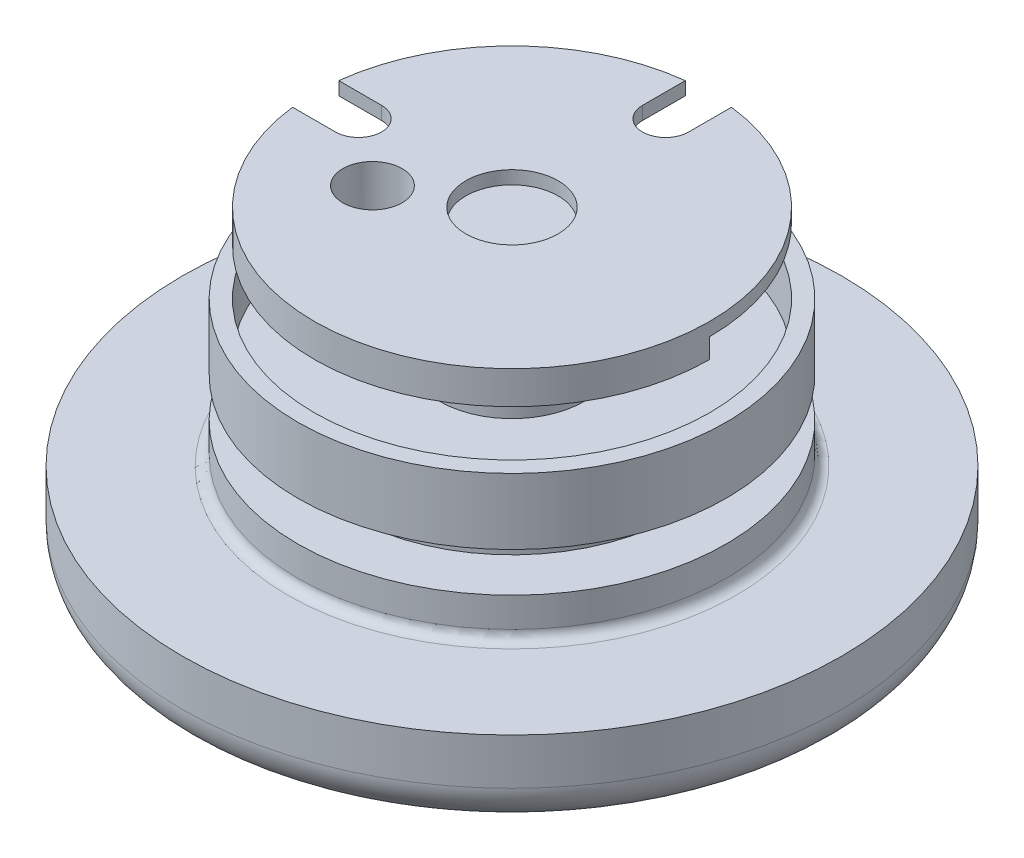
from build123d import *

# Parameters (mm, degrees)
CROQUIS1_R               = 50
SALIENTE_EXTRUIR1_DEPTH  = 13
CROQUIS1_3_R             = 38.5
CORTAR_EXTRUIR1_DEPTH    = 4
CROQUIS4_R               = 14
CROQUIS4_R_2             = 11
SALIENTE_EXTRUIR3_DEPTH  = 6
CROQUIS4_2_R             = 11
CORTAR_EXTRUIR4_DEPTH    = 10
REDONDEO1_R              = 1.5
REDONDEO2_R              = 1.5
REDONDEO3_R              = 6
CROQUIS7_R               = 32.5
CROQUIS7_R_2             = 11
SALIENTE_EXTRUIR4_DEPTH  = 6
REDONDEO4_R              = 1.5
CROQUIS9_R               = 25
CROQUIS9_R_2             = 11
SALIENTE_EXTRUIR6_DEPTH  = 6
CROQUIS10_R              = 32.5
CROQUIS10_R_2            = 11
SALIENTE_EXTRUIR7_DEPTH  = 10
CROQUIS11_R              = 30
CROQUIS11_R_2            = 11
CORTAR_EXTRUIR5_DEPTH    = 8
CROQUIS12_R              = 11
CROQUIS12_R_2            = 7
SALIENTE_EXTRUIR8_DEPTH  = 29
CROQUIS12_2_R            = 11
CROQUIS12_2_R_2          = 7
SALIENTE_EXTRUIR9_DEPTH  = 18
CROQUIS13_R              = 11
CORTAR_EXTRUIR6_DEPTH    = 10
CROQUIS14_R              = 15
SALIENTE_EXTRUIR11_DEPTH = 10
SALIENTE_EXTRUIR12_DEPTH = 8
CORTAR_REVOLUCI_N1_ANGLE = 180
CROQUIS19_R              = 30
CROQUIS19_R_2            = 7
SALIENTE_EXTRUIR13_DEPTH = 2
CORTAR_EXTRUIR9_DEPTH    = 10
CROQUIS21_R              = 4.5
CORTAR_EXTRUIR10_DEPTH   = 10


with BuildPart() as part:
    # Croquis1 → Saliente-Extruir1 (new body)
    with BuildSketch(Plane(origin=(0, 0, 0), x_dir=(1, 0, 0), z_dir=(0, 1, 0))):
        Circle(CROQUIS1_R)
    extrude(amount=SALIENTE_EXTRUIR1_DEPTH)

    # Croquis1_3 → Cortar-Extruir1 (cut)
    with BuildSketch(Plane(origin=(0, 0, 0), x_dir=(1, 0, 0), z_dir=(0, 1, 0))):
        Circle(CROQUIS1_3_R)
    extrude(amount=CORTAR_EXTRUIR1_DEPTH, mode=Mode.SUBTRACT)

    # Croquis4 → Saliente-Extruir3 (add)
    with BuildSketch(Plane.XZ.offset(-4)):
        Circle(CROQUIS4_R)
        Circle(CROQUIS4_R_2, mode=Mode.SUBTRACT)
    extrude(amount=SALIENTE_EXTRUIR3_DEPTH)

    # Croquis4_2 → Cortar-Extruir4 (cut, through all)
    with BuildSketch(Plane.XZ.offset(-4)):
        Circle(CROQUIS4_2_R)
    extrude(amount=-CORTAR_EXTRUIR4_DEPTH, mode=Mode.SUBTRACT)

    # Redondeo1
    redondeo1_edges = [part.edges().sort_by_distance(p)[0] for p in [
        (-38.5, 4, 0),
    ]]
    fillet(redondeo1_edges, radius=REDONDEO1_R)

    # Redondeo2
    redondeo2_edges = [part.edges().sort_by_distance(p)[0] for p in [
        (-14, 4, 0),
    ]]
    fillet(redondeo2_edges, radius=REDONDEO2_R)

    # Redondeo3
    redondeo3_edges = [part.edges().sort_by_distance(p)[0] for p in [
        (-50, 0, 0),
    ]]
    fillet(redondeo3_edges, radius=REDONDEO3_R)

    # Croquis7 → Saliente-Extruir4 (add)
    with BuildSketch(Plane(origin=(0, 13, 0), x_dir=(1, 0, 0), z_dir=(0, 1, 0))):
        Circle(CROQUIS7_R)
        Circle(CROQUIS7_R_2, mode=Mode.SUBTRACT)
    extrude(amount=SALIENTE_EXTRUIR4_DEPTH)

    # Redondeo4
    redondeo4_edges = [part.edges().sort_by_distance(p)[0] for p in [
        (-32.5, 13, 0),
    ]]
    fillet(redondeo4_edges, radius=REDONDEO4_R)

    # Croquis9 → Saliente-Extruir6 (add)
    with BuildSketch(Plane(origin=(0, 19, 0), x_dir=(1, 0, 0), z_dir=(0, 1, 0))):
        Circle(CROQUIS9_R)
        Circle(CROQUIS9_R_2, mode=Mode.SUBTRACT)
    extrude(amount=SALIENTE_EXTRUIR6_DEPTH)

    # Croquis10 → Saliente-Extruir7 (add)
    with BuildSketch(Plane(origin=(0, 25, 0), x_dir=(1, 0, 0), z_dir=(0, 1, 0))):
        Circle(CROQUIS10_R)
        Circle(CROQUIS10_R_2, mode=Mode.SUBTRACT)
    extrude(amount=SALIENTE_EXTRUIR7_DEPTH)

    # Croquis11 → Cortar-Extruir5 (cut)
    with BuildSketch(Plane(origin=(0, 35, 0), x_dir=(1, 0, 0), z_dir=(0, 1, 0))):
        Circle(CROQUIS11_R)
        Circle(CROQUIS11_R_2, mode=Mode.SUBTRACT)
    extrude(amount=-CORTAR_EXTRUIR5_DEPTH, mode=Mode.SUBTRACT)

    # Croquis12 → Saliente-Extruir8 (add, through all)
    with BuildSketch(Plane(origin=(0, 27, 0), x_dir=(1, 0, 0), z_dir=(0, 1, 0))):
        Circle(CROQUIS12_R)
        Circle(CROQUIS12_R_2, mode=Mode.SUBTRACT)
    extrude(amount=-SALIENTE_EXTRUIR8_DEPTH)

    # Croquis12_2 → Saliente-Extruir9 (add)
    with BuildSketch(Plane(origin=(0, 27, 0), x_dir=(1, 0, 0), z_dir=(0, 1, 0))):
        Circle(CROQUIS12_2_R)
        Circle(CROQUIS12_2_R_2, mode=Mode.SUBTRACT)
    extrude(amount=SALIENTE_EXTRUIR9_DEPTH)

    # Croquis13 → Cortar-Extruir6 (cut)
    with BuildSketch(Plane.XZ.offset(2)):
        Circle(CROQUIS13_R)
    extrude(amount=-CORTAR_EXTRUIR6_DEPTH, mode=Mode.SUBTRACT)

    # Croquis14 → Saliente-Extruir11 (add)
    with BuildSketch(Plane(origin=(0, 45, 0), x_dir=(1, 0, 0), z_dir=(0, 1, 0))):
        Circle(CROQUIS14_R)
    extrude(amount=-SALIENTE_EXTRUIR11_DEPTH)

    # Croquis17 → Saliente-Extruir12 (add)
    with BuildSketch(Plane(origin=(0, 45, 0), x_dir=(1, 0, 0), z_dir=(0, 1, 0))):
        with BuildLine():
            Line((30, 0), (15, 0))
            ThreePointArc((15, 0), (0, -15), (-15, 0))
            Line((-15, 0), (-30, 0))
            ThreePointArc((-30, 0), (0, -30), (30, 0))
        make_face()
    extrude(amount=-SALIENTE_EXTRUIR12_DEPTH)

    # Croquis18 → Cortar-Revoluci_n1 (revolve, cut)
    with BuildSketch(Plane(origin=(0, 0, 0), x_dir=(-1, 0, 0), z_dir=(0, 0, -1))):
        Polygon((15, 40), (30, 42), (30, 37), (15, 37), align=None)
    revolve(axis=Axis((0, 37, 0), (0, 1, 0)), revolution_arc=CORTAR_REVOLUCI_N1_ANGLE, mode=Mode.SUBTRACT)

    # Croquis19 → Saliente-Extruir13 (add)
    with BuildSketch(Plane(origin=(0, 45, 0), x_dir=(1, 0, 0), z_dir=(0, 1, 0))):
        Circle(CROQUIS19_R)
        Circle(CROQUIS19_R_2, mode=Mode.SUBTRACT)
    extrude(amount=SALIENTE_EXTRUIR13_DEPTH)

    # Croquis20 → Cortar-Extruir9 (cut)
    with BuildSketch(Plane(origin=(0, 47, 0), x_dir=(1, 0, 0), z_dir=(0, 1, 0))):
        with BuildLine():
            Line((3.505959936, 29.79443312), (3.505959936, 23.29443312))
            ThreePointArc((3.505959936, 23.29443312), (0.005959936, 19.79443312), (-3.494040064, 23.29443312))
            Line((-3.494040064, 23.29443312), (-3.494040064, 29.795833333))
            ThreePointArc((-3.494040064, 29.795833333), (0.006000915, 29.9999994), (3.505959936, 29.79443312))
        make_face()
        with BuildLine():
            Line((-29.79443312, 3.505959936), (-23.29443312, 3.505959936))
            ThreePointArc((-23.29443312, 3.505959936), (-19.79443312, 0.005959936), (-23.29443312, -3.494040064))
            Line((-23.29443312, -3.494040064), (-29.795833333, -3.494040064))
            ThreePointArc((-29.795833333, -3.494040064), (-29.9999994, 0.006000915), (-29.79443312, 3.505959936))
        make_face()
    extrude(amount=-CORTAR_EXTRUIR9_DEPTH, mode=Mode.SUBTRACT)

    # Croquis21 → Cortar-Extruir10 (cut)
    with BuildSketch(Plane(origin=(0, 47, 0), x_dir=(1, 0, 0), z_dir=(0, 1, 0))):
        with Locations((-13.423393759, -7.75)):
            Circle(CROQUIS21_R)
    extrude(amount=-CORTAR_EXTRUIR10_DEPTH, mode=Mode.SUBTRACT)


solid = part.part
